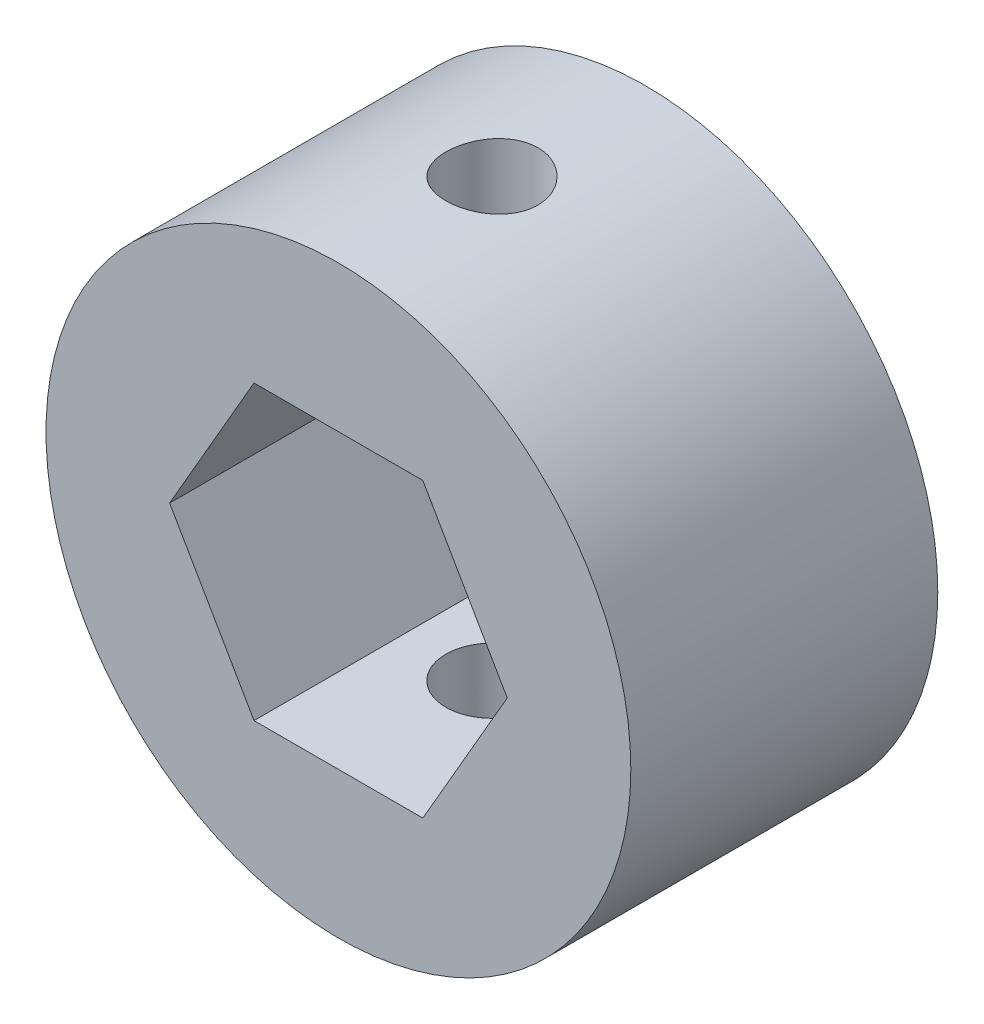
from build123d import *

# Parameters (mm, degrees)
SKETCH2_R               = 9.525
BOSS_EXTRUDE1_DEPTH     = 10
SKETCH3_R               = 1.5
CUT_EXTRUDE1_DEPTH      = 15.2875
CUT_EXTRUDE1_DEPTH_BACK = 5.7625


with BuildPart() as part:
    # Sketch2 → Boss-Extrude1 (new body)
    with BuildSketch(Plane.XY):
        Circle(SKETCH2_R)
        Polygon((5.499261314, 0), (2.749630657, 4.7625), (-2.749630657, 4.7625), (-5.499261314, 0), (-2.749630657, -4.7625), (2.749630657, -4.7625), align=None, mode=Mode.SUBTRACT)
    extrude(amount=BOSS_EXTRUDE1_DEPTH)

    # Sketch3 → Cut-Extrude1 (cut, two sides)
    with BuildSketch(Plane(origin=(0, -4.7625, 0), x_dir=(1, 0, 0), z_dir=(0, 1, 0))) as cut_extrude1_sk:
        with Locations((0, -5)):
            Circle(SKETCH3_R)
    extrude(amount=CUT_EXTRUDE1_DEPTH, mode=Mode.SUBTRACT)
    extrude(cut_extrude1_sk.sketch, amount=-CUT_EXTRUDE1_DEPTH_BACK, mode=Mode.SUBTRACT)


solid = part.part
